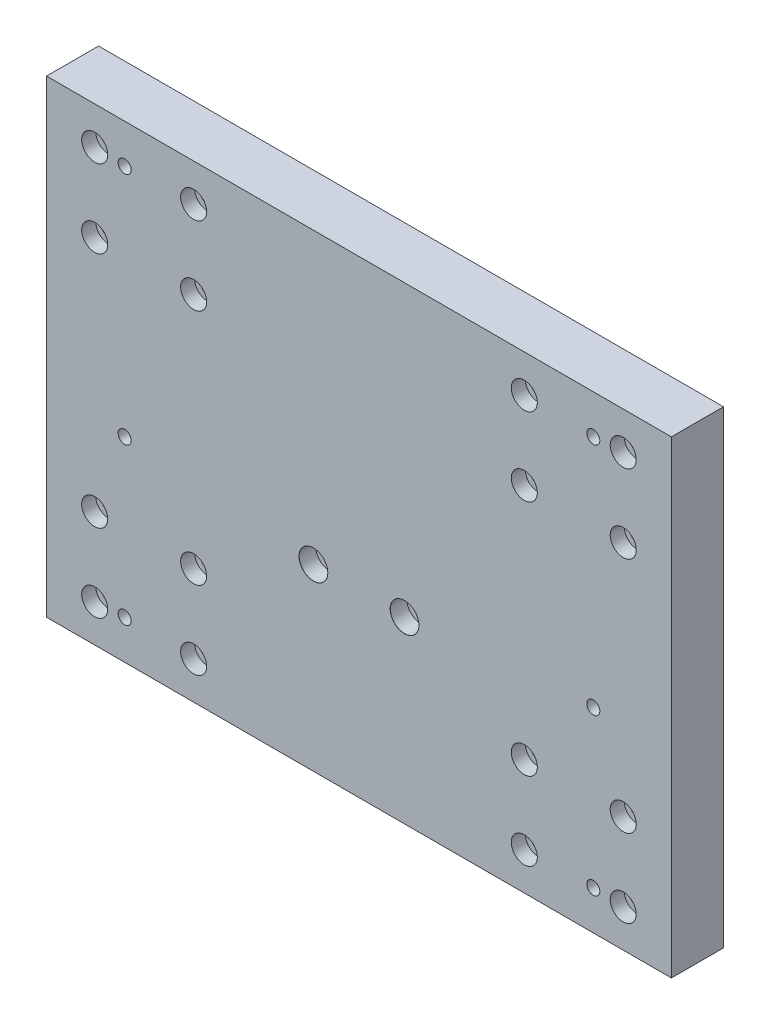
from build123d import *

# Parameters (mm, degrees)
SKETCH2_W                                           = 240
SKETCH2_H                                           = 180
EXTRUDE1_DEPTH                                      = 20
CBORE_FOR_M5_HEX_SOCKET_HEAD_CAP_SCREW1_D           = 5.5
CBORE_FOR_M5_HEX_SOCKET_HEAD_CAP_SCREW1_DEPTH       = 29
CBORE_FOR_M5_HEX_SOCKET_HEAD_CAP_SCREW1_CBORE_D     = 10
CBORE_FOR_M5_HEX_SOCKET_HEAD_CAP_SCREW1_CBORE_DEPTH = 5.4
CBORE_FOR_M5_HEX_SOCKET_HEAD_CAP_SCREW1_TIP         = 1.652366702
M6_TAPPED_HOLE1_D                                   = 5
CBORE_FOR_M6_HEX_SOCKET_HEAD_CAP_SCR_2_COUNT        = 2
CBORE_FOR_M6_HEX_SOCKET_HEAD_CAP_SCR_2_PITCH        = 35


with BuildPart() as part:
    # Sketch2 → Extrude1 (new body)
    with BuildSketch(Plane.XY):
        Rectangle(SKETCH2_W, SKETCH2_H)
    extrude(amount=EXTRUDE1_DEPTH)

    # CBORE for M5 Hex Socket Head Cap Screw1
    with Locations(Plane.XY.offset(20)):
        with Locations((-101.5, 75.6), (-63.5, 75.6), (-63.5, 45.6), (-101.5, 45.6), (63.5, 75.6), (101.5, 75.6), (101.5, 45.6), (63.5, 45.6), (101.5, -45.6), (63.5, -45.6), (63.5, -75.6), (101.5, -75.6), (-63.5, -75.6), (-63.5, -45.6), (-101.5, -45.6), (-101.5, -75.6)):
            CounterBoreHole(CBORE_FOR_M5_HEX_SOCKET_HEAD_CAP_SCREW1_D / 2, CBORE_FOR_M5_HEX_SOCKET_HEAD_CAP_SCREW1_CBORE_D / 2, CBORE_FOR_M5_HEX_SOCKET_HEAD_CAP_SCREW1_CBORE_DEPTH, depth=CBORE_FOR_M5_HEX_SOCKET_HEAD_CAP_SCREW1_DEPTH)
            with Locations((0, 0, -(CBORE_FOR_M5_HEX_SOCKET_HEAD_CAP_SCREW1_DEPTH + CBORE_FOR_M5_HEX_SOCKET_HEAD_CAP_SCREW1_TIP / 2))):  # 118° drill point
                Cone(0, CBORE_FOR_M5_HEX_SOCKET_HEAD_CAP_SCREW1_D / 2, CBORE_FOR_M5_HEX_SOCKET_HEAD_CAP_SCREW1_TIP, mode=Mode.SUBTRACT)

    # M6 Tapped Hole1 (through all)
    with Locations(Plane.XY.offset(20)):
        with Locations((-90, 75), (90, 75), (90, -15), (90, -75), (-90, -15), (-90, -75)):
            Hole(M6_TAPPED_HOLE1_D / 2)

    # Sketch8 → CBORE for M6 Hex Socket Head Cap Screw1 (revolve, cut)
    with BuildSketch(Plane(origin=(17.5, -21.2, 20), x_dir=(0, -1, 0), z_dir=(1, 0, 0))):
        Polygon((0, 0), (0, 13.482840043), (3.3, 11.5), (3.3, 6.4), (5.5, 6.4), (5.5, 0.025), (5.525, 0), align=None)
    cbore_for_m6_hex_socket_head_cap_screw1 = revolve(axis=Axis((17.5, -21.2, 26.35), (0, 0, -1)), mode=Mode.SUBTRACT)

    # CBORE for M6 Hex Socket Head Cap Scr 2: CBORE for M6 Hex Socket Head Cap Screw1 ×2
    with Locations(*[(-i * CBORE_FOR_M6_HEX_SOCKET_HEAD_CAP_SCR_2_PITCH, 0, 0) for i in range(1, CBORE_FOR_M6_HEX_SOCKET_HEAD_CAP_SCR_2_COUNT)]):
        add(cbore_for_m6_hex_socket_head_cap_screw1, mode=Mode.SUBTRACT)


solid = part.part
